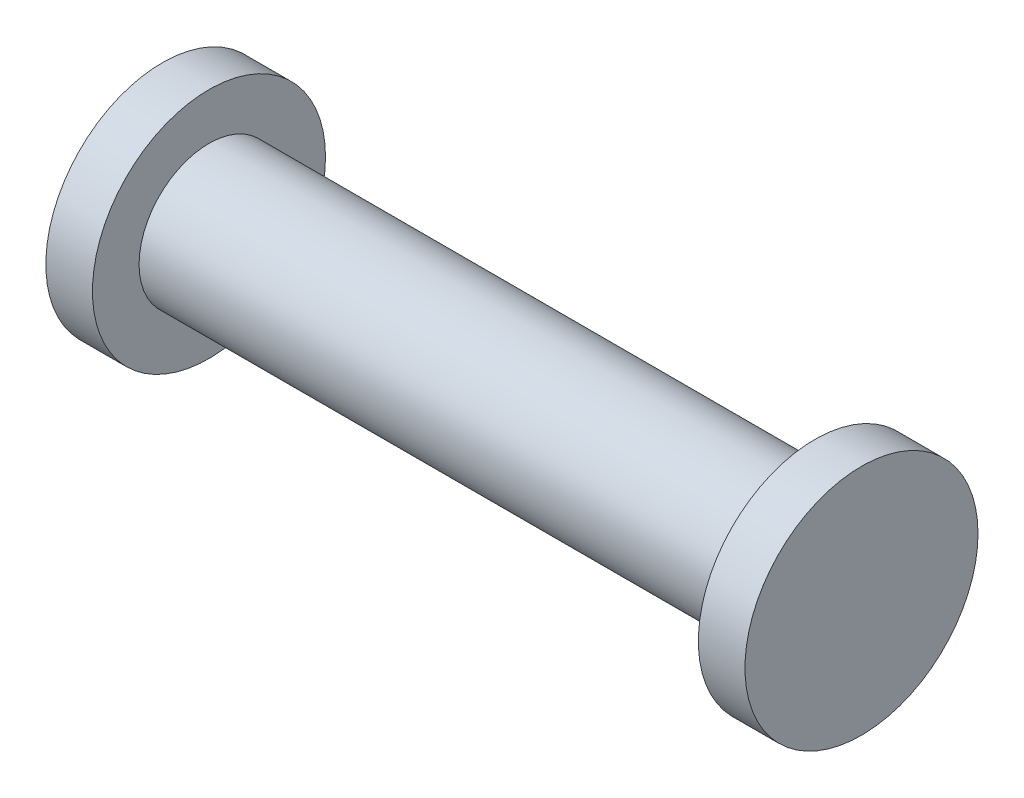
from build123d import *

# Parameters (mm, degrees)
SKETCH1_R           = 7.5
BOSS_EXTRUDE1_DEPTH = 32.5
SKETCH4_R           = 12.5
BOSS_EXTRUDE3_DEPTH = 5


with BuildPart() as part:
    # Sketch1 → Boss-Extrude1 (new body, symmetric)
    with BuildSketch(Plane(origin=(0, 0, 0), x_dir=(0, 0, -1), z_dir=(1, 0, 0))):
        Circle(SKETCH1_R)
    extrude(amount=BOSS_EXTRUDE1_DEPTH, both=True)

    # Sketch4 → Boss-Extrude3 (add)
    with BuildSketch(Plane(origin=(32.5, 0, 0), x_dir=(0, 0, -1), z_dir=(1, 0, 0))):
        Circle(SKETCH4_R)
    boss_extrude3 = extrude(amount=BOSS_EXTRUDE3_DEPTH)

    # Mirror1: Boss-Extrude3 across plane
    add(boss_extrude3.mirror(Plane(origin=(0, 0, 0), x_dir=(0, 0, 1), z_dir=(1, 0, 0))))


solid = part.part
